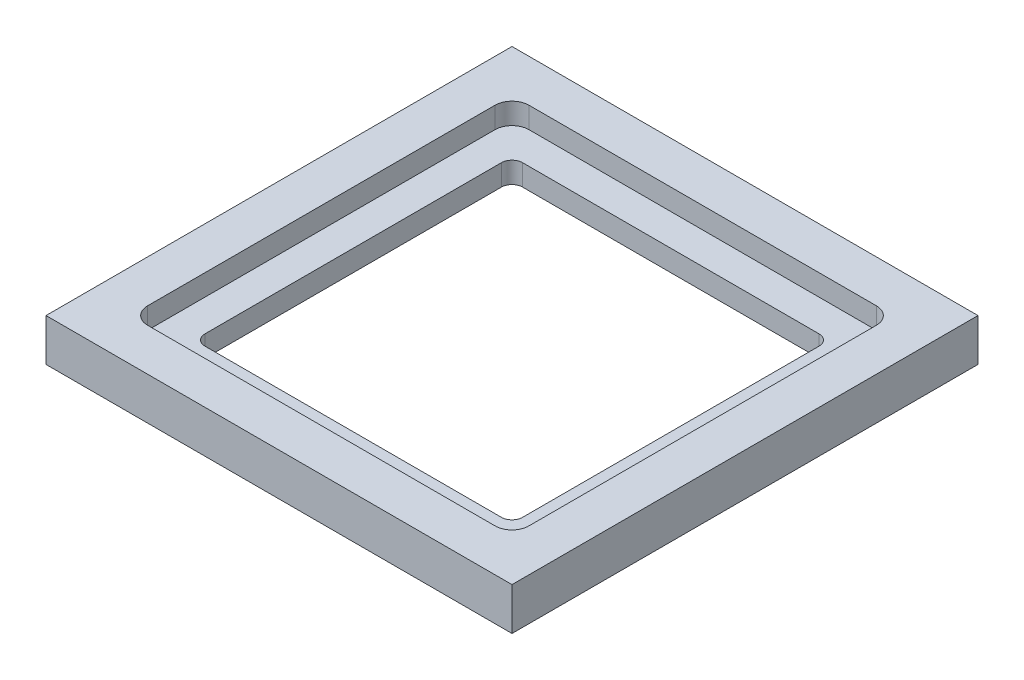
from build123d import *

# Parameters (mm, degrees)
SKETCH1_W           = 44
SKETCH1_H           = 44
SKETCH1_W_2         = 36
SKETCH1_H_2         = 36
BOSS_EXTRUDE1_DEPTH = 2
FILLET1_R           = 1.6
SKETCH2_W           = 44
SKETCH2_H           = 44
SKETCH2_W_2         = 30
SKETCH2_H_2         = 30
BOSS_EXTRUDE2_DEPTH = 2
FILLET2_R           = 1


with BuildPart() as part:
    # Sketch1 → Boss-Extrude1 (new body)
    with BuildSketch(Plane(origin=(0, 0, 0), x_dir=(1, 0, 0), z_dir=(0, 1, 0))):
        Rectangle(SKETCH1_W, SKETCH1_H)
        Rectangle(SKETCH1_W_2, SKETCH1_H_2, mode=Mode.SUBTRACT)
    extrude(amount=BOSS_EXTRUDE1_DEPTH)

    # Fillet1
    fillet1_edges = [part.edges().sort_by_distance(p)[0] for p in [
        (18, 1, -18),
        (-18, 1, -18),
        (-18, 1, 18),
        (18, 1, 18),
    ]]
    fillet(fillet1_edges, radius=FILLET1_R)

    # Sketch2 → Boss-Extrude2 (add)
    with BuildSketch(Plane.XZ):
        Rectangle(SKETCH2_W, SKETCH2_H)
        Rectangle(SKETCH2_W_2, SKETCH2_H_2, mode=Mode.SUBTRACT)
    extrude(amount=BOSS_EXTRUDE2_DEPTH)

    # Fillet2
    fillet2_edges = [part.edges().sort_by_distance(p)[0] for p in [
        (15, -1, 15),
        (-15, -1, 15),
        (-15, -1, -15),
        (15, -1, -15),
    ]]
    fillet(fillet2_edges, radius=FILLET2_R)


solid = part.part
